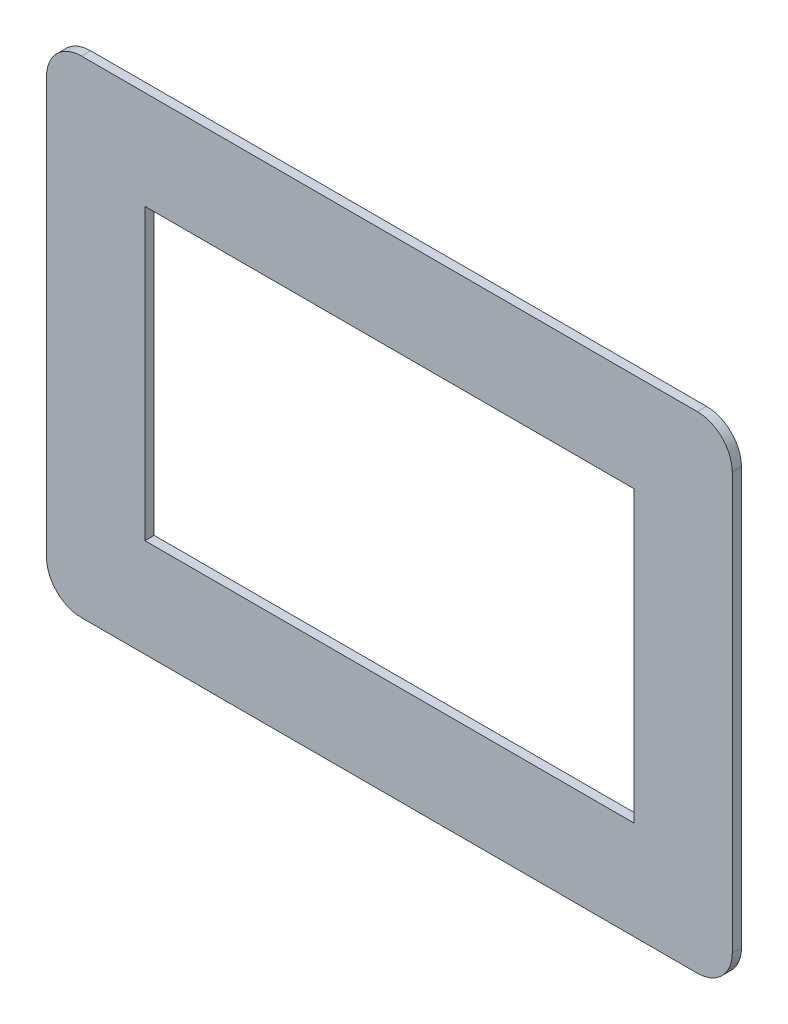
from build123d import *

# Parameters (mm, degrees)
SKETCH1_W           = 154
SKETCH1_H           = 91.2
BOSS_EXTRUDE1_DEPTH = 2.9
CUT_EXTRUDE3_DEPTH  = 1.5


with BuildPart() as part:
    # Sketch1 → Boss-Extrude1 (new body)
    with BuildSketch(Plane.XY):
        with BuildLine():
            Line((99.87625, 76.6), (-94.12375, 76.6))
            ThreePointArc((-94.12375, 76.6), (-101.901924593, 73.378174593), (-105.12375, 65.6))
            Line((-105.12375, 65.6), (-105.12375, -65.6))
            ThreePointArc((-105.12375, -65.6), (-101.901924593, -73.378174593), (-94.12375, -76.6))
            Line((-94.12375, -76.6), (99.87625, -76.6))
            ThreePointArc((99.87625, -76.6), (107.654424593, -73.378174593), (110.87625, -65.6))
            Line((110.87625, -65.6), (110.87625, 65.6))
            ThreePointArc((110.87625, 65.6), (107.654424593, 73.378174593), (99.87625, 76.6))
        make_face()
        with Locations((2.87625, 0)):
            Rectangle(SKETCH1_W, SKETCH1_H, mode=Mode.SUBTRACT)
    extrude(amount=BOSS_EXTRUDE1_DEPTH)

    # Sketch2 → Cut-Extrude3 (cut)
    with BuildSketch(Plane.XY):
        with BuildLine():
            Line((99.87625, 75.6), (-94.12375, 75.6))
            ThreePointArc((-94.12375, 75.6), (-101.194817812, 72.671067812), (-104.12375, 65.6))
            Line((-104.12375, 65.6), (-104.12375, -65.6))
            ThreePointArc((-104.12375, -65.6), (-101.194817812, -72.671067812), (-94.12375, -75.6))
            Line((-94.12375, -75.6), (99.87625, -75.6))
            ThreePointArc((99.87625, -75.6), (106.947317812, -72.671067812), (109.87625, -65.6))
            Line((109.87625, -65.6), (109.87625, 65.6))
            ThreePointArc((109.87625, 65.6), (106.947317812, 72.671067812), (99.87625, 75.6))
        make_face()
        with BuildLine():
            Line((99.87625, 73.6), (-94.12375, 73.6))
            ThreePointArc((-94.12375, 73.6), (-99.780604249, 71.256854249), (-102.12375, 65.6))
            Line((-102.12375, 65.6), (-102.12375, -65.6))
            ThreePointArc((-102.12375, -65.6), (-99.780604249, -71.256854249), (-94.12375, -73.6))
            Line((-94.12375, -73.6), (99.87625, -73.6))
            ThreePointArc((99.87625, -73.6), (105.533104249, -71.256854249), (107.87625, -65.6))
            Line((107.87625, -65.6), (107.87625, 65.6))
            ThreePointArc((107.87625, 65.6), (105.533104249, 71.256854249), (99.87625, 73.6))
        make_face(mode=Mode.SUBTRACT)
    extrude(amount=CUT_EXTRUDE3_DEPTH, mode=Mode.SUBTRACT)


solid = part.part
